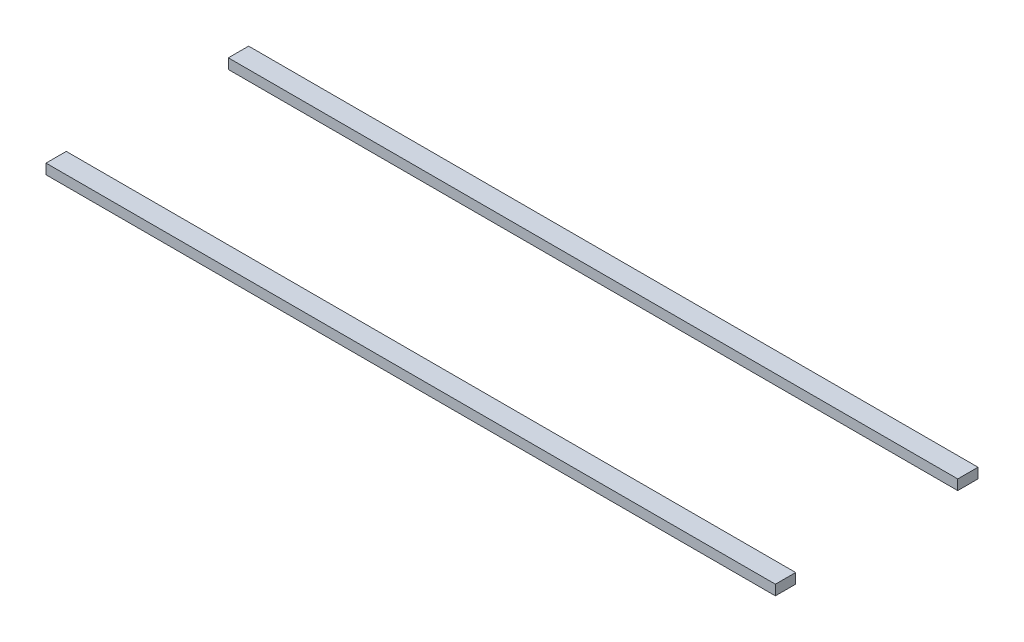
from build123d import *

# Parameters (mm, degrees)
SKETCH1_W             = 274.32
SKETCH1_H             = 7.62
BOSS_EXTRUDE1_DEPTH   = 3.81
BOSS_EXTRUDE1_2_DEPTH = 3.81


with BuildPart() as part:
    # Sketch1 → Boss-Extrude1 (new body)
    with BuildSketch(Plane(origin=(0, 0, 0), x_dir=(1, 0, 0), z_dir=(0, 1, 0))):
        with Locations((0, -34.29)):
            Rectangle(SKETCH1_W, SKETCH1_H)
    extrude(amount=BOSS_EXTRUDE1_DEPTH)


with BuildPart() as body_2:
    # Sketch1 → Boss-Extrude1 2 (new body)
    with BuildSketch(Plane(origin=(0, 0, 0), x_dir=(1, 0, 0), z_dir=(0, 1, 0))):
        with Locations((0, 34.29)):
            Rectangle(SKETCH1_W, SKETCH1_H)
    extrude(amount=BOSS_EXTRUDE1_2_DEPTH)


solid = Compound([part.part, body_2.part])
